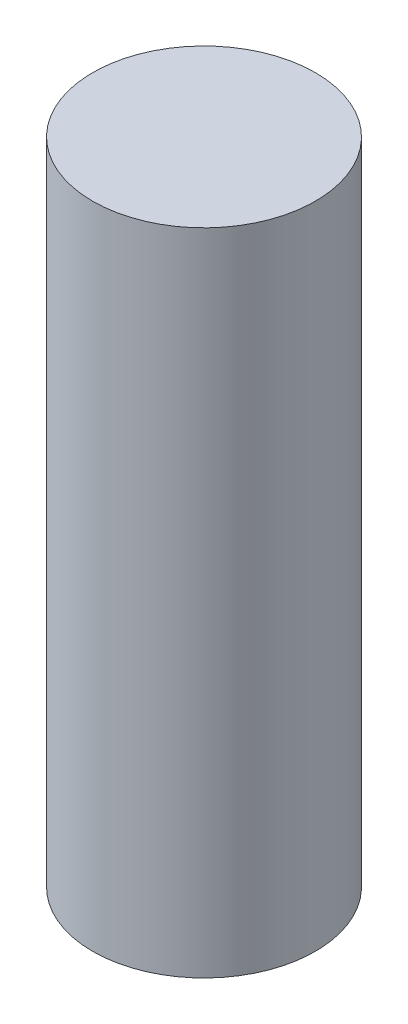
from build123d import *

# Parameters (mm, degrees)
SKETCH1_R           = 6
BOSS_EXTRUDE1_DEPTH = 35


with BuildPart() as part:
    # Sketch1 → Boss-Extrude1 (new body)
    with BuildSketch(Plane(origin=(0, 0, 0), x_dir=(1, 0, 0), z_dir=(0, 1, 0))):
        with Locations((-15.766129032, 9.853830645)):
            Circle(SKETCH1_R)
    extrude(amount=BOSS_EXTRUDE1_DEPTH)


solid = part.part
